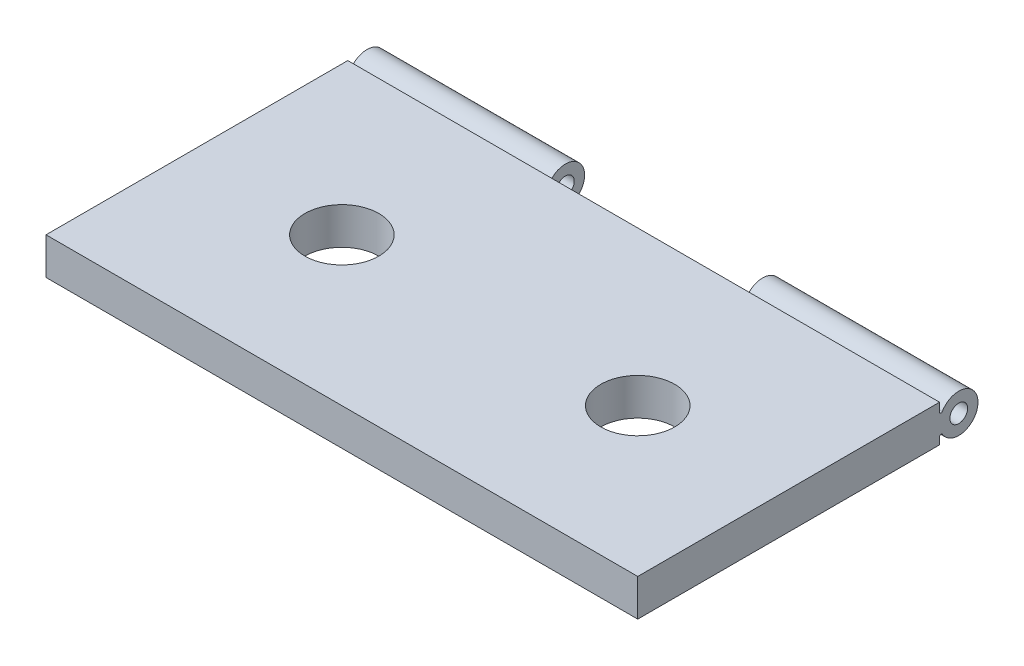
from build123d import *

# Parameters (mm, degrees)
CROQUIS3_W              = 50.8
CROQUIS3_H              = 25.4
CROQUIS3_R              = 3.175
SALIENTE_EXTRUIR1_DEPTH = 3.175
CROQUIS6_R              = 0.762
SALIENTE_EXTRUIR3_DEPTH = 8.466666667
CROQUIS7_R              = 0.762
SALIENTE_EXTRUIR4_DEPTH = 50.8
CROQUIS8_W              = 16.933333333
CROQUIS8_H              = 3.302
CORTAR_EXTRUIR2_DEPTH   = 25.4


with BuildPart() as part:
    # Croquis3 → Saliente-Extruir1 (new body)
    with BuildSketch(Plane(origin=(0, 0, 0), x_dir=(1, 0, 0), z_dir=(0, 1, 0))):
        Rectangle(CROQUIS3_W, CROQUIS3_H)
        with Locations((-12.7, 0)):
            Circle(CROQUIS3_R, mode=Mode.SUBTRACT)
        with Locations((12.7, 0)):
            Circle(CROQUIS3_R, mode=Mode.SUBTRACT)
    extrude(amount=SALIENTE_EXTRUIR1_DEPTH)

    # Croquis6 → Saliente-Extruir3 (add, symmetric)
    with BuildSketch(Plane.ZY):
        with BuildLine():
            Line((-12.7, 3.175), (-13.208, 3.175))
            Line((-13.208, 3.175), (-13.208, 2.437497499))
            ThreePointArc((-13.208, 2.437497499), (-13.301057822, 2.315117237), (-13.443857143, 2.372082497))
            ThreePointArc((-13.443857143, 2.372082497), (-16.51, 1.521687475), (-13.443857143, 0.671292453))
            ThreePointArc((-13.443857143, 0.671292453), (-13.301057822, 0.728257713), (-13.208, 0.605877451))
            Line((-13.208, 0.605877451), (-13.208, 0))
            Line((-13.208, 0), (-12.7, 0))
            Line((-12.7, 0), (-12.7, 3.175))
        make_face()
        with Locations((-14.859, 1.521687475)):
            Circle(CROQUIS6_R, mode=Mode.SUBTRACT)
    extrude(amount=SALIENTE_EXTRUIR3_DEPTH, both=True)

    # Croquis7 → Saliente-Extruir4 (add)
    with BuildSketch(Plane(origin=(25.4, 0, 0), x_dir=(0, 0, -1), z_dir=(1, 0, 0))):
        with BuildLine():
            Line((12.7, 3.175), (13.208, 3.175))
            Line((13.208, 3.175), (13.208, 2.437497499))
            ThreePointArc((13.208, 2.437497499), (13.301057822, 2.315117237), (13.443857143, 2.372082497))
            ThreePointArc((13.443857143, 2.372082497), (16.51, 1.521687475), (13.443857143, 0.671292453))
            ThreePointArc((13.443857143, 0.671292453), (13.301057822, 0.728257713), (13.208, 0.605877451))
            Line((13.208, 0.605877451), (13.208, 0))
            Line((13.208, 0), (12.7, 0))
            Line((12.7, 0), (12.7, 3.175))
        make_face()
        with Locations((14.859, 1.521687475)):
            Circle(CROQUIS7_R, mode=Mode.SUBTRACT)
    extrude(amount=-SALIENTE_EXTRUIR4_DEPTH)

    # Croquis8 → Cortar-Extruir2 (cut)
    with BuildSketch(Plane(origin=(0, 3.175, 0), x_dir=(1, 0, 0), z_dir=(0, 1, 0))):
        with Locations((0.09605237, 14.859)):
            Rectangle(CROQUIS8_W, CROQUIS8_H)
    extrude(amount=-CORTAR_EXTRUIR2_DEPTH, mode=Mode.SUBTRACT)


solid = part.part
